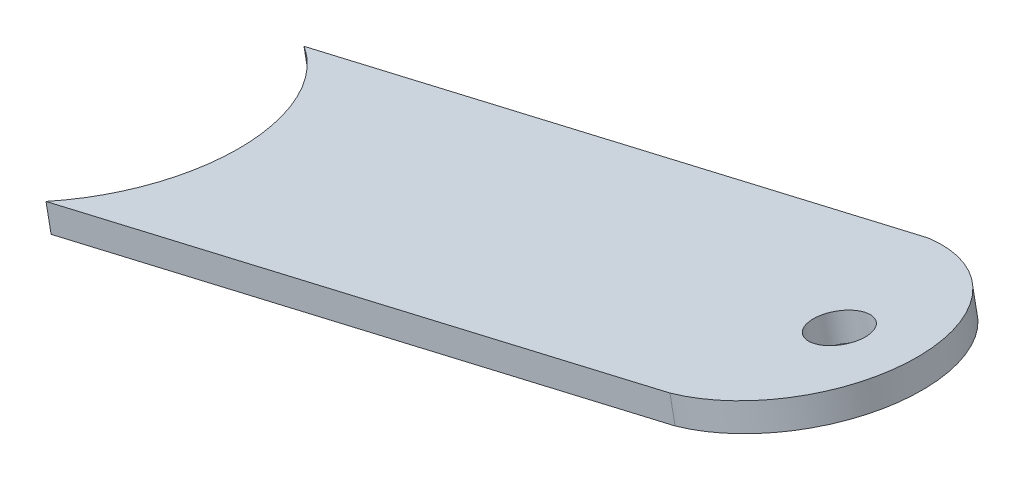
from build123d import *

# Parameters (mm, degrees)
DODANIE_WYCI_GNI_CIE1_DEPTH      = 1.5
DODANIE_WYCI_GNI_CIE1_DEPTH_BACK = 0.5
SZKIC2_R                         = 2
WYTNIJ_WYCI_GNI_CIE1_DEPTH       = 13.403470929


with BuildPart() as part:
    # Szkic1 → Dodanie-wyciągnięcie1 (new body, two sides)
    with BuildSketch(Plane(origin=(91.00215608, -464.566516042, 0), x_dir=(-0.981349358, -0.192232768, 0), z_dir=(0.192232768, -0.981349358, 0))) as dodanie_wyci_gni_cie1_sk:
        with BuildLine():
            Line((-852.646385939, -589.810571865), (-898.412669563, -587.572467385))
            ThreePointArc((-898.412669563, -587.572467385), (-907.277284225, -577.338883089), (-897.89920424, -567.573676668))
            Line((-897.89920424, -567.573676668), (-852.132920616, -569.811781148))
            add(Edge.make_bspline(
                [(-852.646385939, -589.810571865), (-859.599431487, -584.423041675), (-860.017825744, -575.312195542), (-852.132920616, -569.811781148)],
                knots=[-0.289090194, -0.289090194, -0.289090194, -0.289090194, 0.984325659, 0.984325659, 0.984325659, 0.984325659], degree=3, weights=[1.203316353, 0.837838315, 0.76726036, 0.991582488]))
        make_face()
    extrude(amount=DODANIE_WYCI_GNI_CIE1_DEPTH)
    extrude(dodanie_wyci_gni_cie1_sk.sketch, amount=-DODANIE_WYCI_GNI_CIE1_DEPTH_BACK)

    # Szkic2 → Wytnij-wyciągnięcie1 (cut, through all)
    with BuildSketch(Plane(origin=(91.290505232, -466.038540079, 0), x_dir=(-0.981349358, -0.192232768, 0), z_dir=(0.192232768, -0.981349358, 0))):
        with Locations((-901.117736464, -577.428231407)):
            Circle(SZKIC2_R)
    extrude(amount=-WYTNIJ_WYCI_GNI_CIE1_DEPTH, mode=Mode.SUBTRACT)


solid = part.part
